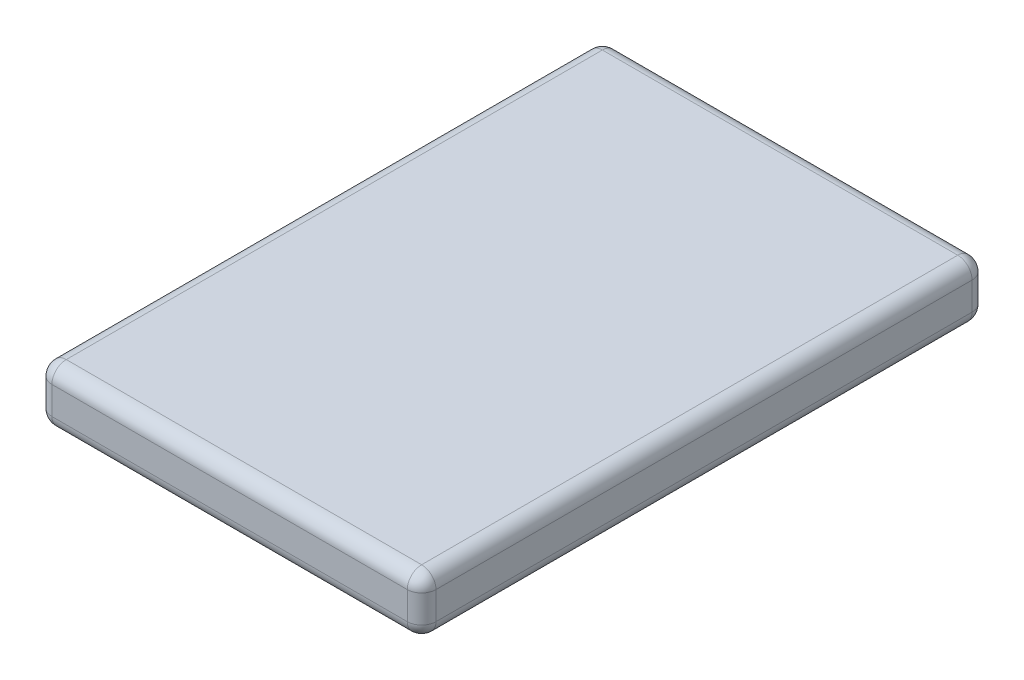
from build123d import *

# Parameters (mm, degrees)
BOSS_EXTRUDE1_DEPTH = 50.000000076
FILLET1_R           = 1.27


with BuildPart() as part:
    # Sketch2 → Boss-Extrude1 (new body)
    with BuildSketch(Plane.XY):
        with BuildLine():
            Line((-15.73, -2.5), (15.73, -2.5))
            ThreePointArc((15.73, -2.5), (16.628025612, -2.128025612), (17, -1.23))
            Line((17, -1.23), (17, 1.23))
            ThreePointArc((17, 1.23), (16.628025612, 2.128025612), (15.73, 2.5))
            Line((15.73, 2.5), (-15.73, 2.5))
            ThreePointArc((-15.73, 2.5), (-16.628025612, 2.128025612), (-17, 1.23))
            Line((-17, 1.23), (-17, -1.23))
            ThreePointArc((-17, -1.23), (-16.628025612, -2.128025612), (-15.73, -2.5))
        make_face()
    extrude(amount=BOSS_EXTRUDE1_DEPTH)

    # Fillet1
    fillet1_edges = [part.edges().sort_by_distance(p)[0] for p in [
        (17, 0, 0),
        (16.628025612, -2.128025612, 0),
        (0, -2.5, 0),
        (-16.628025612, -2.128025612, 0),
        (16.628025612, -2.128025612, 50.000000076),
        (17, 0, 50.000000076),
        (16.628025612, 2.128025612, 50.000000076),
        (0, 2.5, 50.000000076),
        (-16.628025612, 2.128025612, 50.000000076),
        (-17, 0, 50.000000076),
        (-16.628025612, -2.128025612, 50.000000076),
        (-17, 0, 0),
        (0, -2.5, 50.000000076),
        (-16.628025612, 2.128025612, 0),
        (0, 2.5, 0),
        (16.628025612, 2.128025612, 0),
    ]]
    fillet(fillet1_edges, radius=FILLET1_R)


solid = part.part
